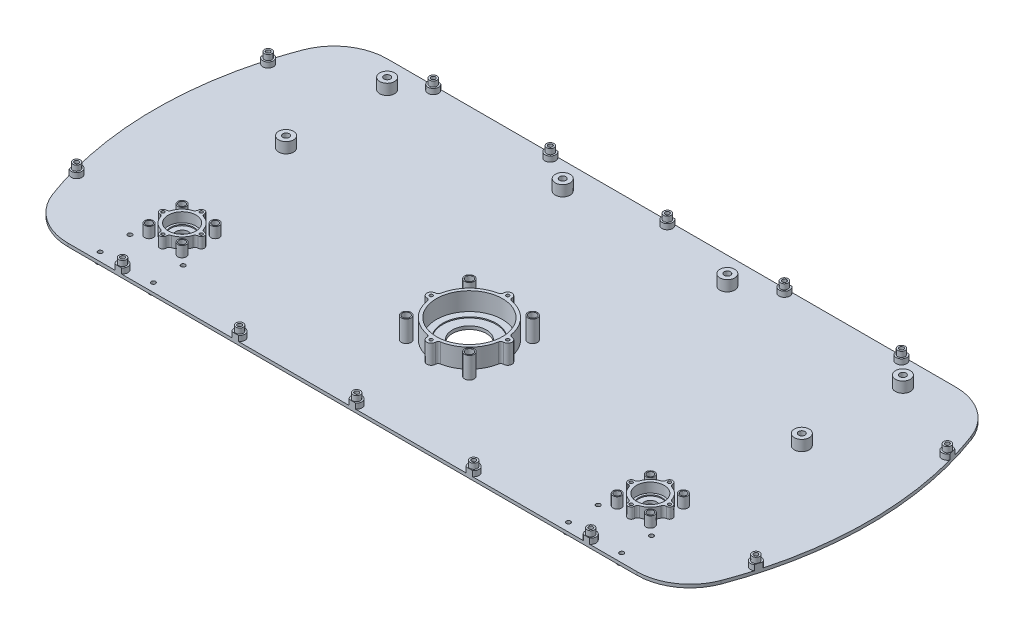
from build123d import *

# Parameters (mm, degrees)
BOSS_EXTRUDE1_DEPTH                          = 3
SKETCH2_R                                    = 6
CUT_EXTRUDE1_DEPTH                           = 10
SKETCH2_3_R                                  = 13
SKETCH2_3_R_2                                = 11
BOSS_EXTRUDE2_DEPTH                          = 1
SKETCH2_4_R                                  = 16
SKETCH2_4_R_2                                = 13
SKETCH2_4_R_3                                = 1.5
BOSS_EXTRUDE3_DEPTH                          = 10
SKETCH3_R                                    = 16
CUT_EXTRUDE8_DEPTH                           = 10
SKETCH3_3_R                                  = 31
SKETCH3_3_R_2                                = 25
BOSS_EXTRUDE4_DEPTH                          = 1
SKETCH3_4_R                                  = 34
SKETCH3_4_R_2                                = 31
SKETCH3_4_R_3                                = 1.5
BOSS_EXTRUDE5_DEPTH                          = 18
SKETCH4_R                                    = 4.5
SKETCH4_R_2                                  = 3.5
SKETCH4_R_3                                  = 2
BOSS_EXTRUDE6_DEPTH                          = 20
CUT_EXTRUDE9_START                           = 20
SKETCH4_3_R                                  = 3.5
SKETCH4_3_R_2                                = 2
CUT_EXTRUDE9_DEPTH                           = 5
SKETCH5_R                                    = 4
SKETCH5_R_2                                  = 3
SKETCH5_R_3                                  = 1.5
BOSS_EXTRUDE7_DEPTH                          = 10
CUT_EXTRUDE10_START                          = 10
SKETCH5_3_R                                  = 3
SKETCH5_3_R_2                                = 1.5
CUT_EXTRUDE10_DEPTH                          = 5
SKETCH8_R                                    = 3.525
SKETCH8_R_2                                  = 2
BOSS_EXTRUDE8_DEPTH                          = 5
SKETCH8_3_R                                  = 2
CUT_EXTRUDE11_DEPTH                          = 10
SKETCH9_R                                    = 2
CUT_EXTRUDE12_DEPTH                          = 10
BOSS_EXTRUDE9_START                          = -3
SKETCH9_3_R                                  = 3.5
SKETCH9_3_R_2                                = 2
BOSS_EXTRUDE9_DEPTH                          = 10
LPATTERN1_COUNT                              = 3
LPATTERN1_PITCH                              = 110
LPATTERN2_COUNT                              = 3
LPATTERN2_PITCH                              = 110
MIRROR4_COPY_1_SKETCH_R                      = 2
MIRROR4_COPY_1_DEPTH                         = 10
MIRROR4_COPY_2_SKETCH_R                      = 2
MIRROR4_COPY_2_DEPTH                         = 10
MIRROR4_START                                = -3
MIRROR4_COPY_3_SKETCH_R                      = 3.5
MIRROR4_COPY_3_SKETCH_R_2                    = 2
MIRROR4_COPY_3_DEPTH                         = 10
MIRROR4_COPY_4_SKETCH_R                      = 3.5
MIRROR4_COPY_4_SKETCH_R_2                    = 2
MIRROR4_COPY_4_DEPTH                         = 10
MIRROR4_COPY_5_SKETCH_R                      = 2
MIRROR4_COPY_5_DEPTH                         = 10
MIRROR4_COPY_6_SKETCH_R                      = 2
MIRROR4_COPY_6_DEPTH                         = 10
MIRROR4_COPY_7_SKETCH_R                      = 2
MIRROR4_COPY_7_DEPTH                         = 10
MIRROR4_COPY_8_SKETCH_R                      = 3.5
MIRROR4_COPY_8_SKETCH_R_2                    = 2
MIRROR4_COPY_8_DEPTH                         = 10
MIRROR4_COPY_9_SKETCH_R                      = 3.5
MIRROR4_COPY_9_SKETCH_R_2                    = 2
MIRROR4_COPY_9_DEPTH                         = 10
MIRROR4_COPY_10_SKETCH_R                     = 2
MIRROR4_COPY_10_DEPTH                        = 10
SKETCH9_5_R                                  = 2
CUT_EXTRUDE13_DEPTH                          = 10
BOSS_EXTRUDE10_START                         = -3
SKETCH9_6_R                                  = 3.5
SKETCH9_6_R_2                                = 2
BOSS_EXTRUDE10_DEPTH                         = 10
MIRROR9_AT_THE_SECOND_PLANE_COPY_1_SKETC_R   = 2
MIRROR9_AT_THE_SECOND_PLANE_COPY_1_DEPTH     = 10
MIRROR9_START                                = -3
MIRROR9_AT_THE_SECOND_PLANE_COPY_2_SKETC_R   = 3.5
MIRROR9_AT_THE_SECOND_PLANE_COPY_2_SKETC_R_2 = 2
MIRROR9_AT_THE_SECOND_PLANE_COPY_2_DEPTH     = 10
BOSS_EXTRUDE11_START                         = -3
SKETCH9_7_R                                  = 3.5
BOSS_EXTRUDE11_DEPTH                         = 5
LPATTERN3_COUNT                              = 3
LPATTERN3_PITCH                              = 110
LPATTERN4_START                              = -3
LPATTERN4_COPY_1_SKETCH_R                    = 3.5
LPATTERN4_COPY_1_DEPTH                       = 5
LPATTERN4_COPY_2_SKETCH_R                    = 3.5
LPATTERN4_COPY_2_DEPTH                       = 5
LPATTERN4_COPY_3_SKETCH_R                    = 3.5
LPATTERN4_COPY_3_DEPTH                       = 5
LPATTERN4_COPY_4_SKETCH_R                    = 3.5
LPATTERN4_COPY_4_DEPTH                       = 5
LPATTERN4_COPY_5_SKETCH_R                    = 3.5
LPATTERN4_COPY_5_DEPTH                       = 5
LPATTERN4_COPY_6_SKETCH_R                    = 3.5
LPATTERN4_COPY_6_DEPTH                       = 5
MIRROR10_START                               = -3
MIRROR10_COPY_1_SKETCH_R                     = 3.5
MIRROR10_COPY_1_DEPTH                        = 5
MIRROR10_COPY_2_SKETCH_R                     = 3.5
MIRROR10_COPY_2_DEPTH                        = 5
MIRROR10_COPY_3_SKETCH_R                     = 3.5
MIRROR10_COPY_3_DEPTH                        = 5
MIRROR10_COPY_4_SKETCH_R                     = 3.5
MIRROR10_COPY_4_DEPTH                        = 5
MIRROR10_COPY_5_SKETCH_R                     = 3.5
MIRROR10_COPY_5_DEPTH                        = 5
MIRROR10_COPY_6_SKETCH_R                     = 3.5
MIRROR10_COPY_6_DEPTH                        = 5
MIRROR10_COPY_7_SKETCH_R                     = 3.5
MIRROR10_COPY_7_DEPTH                        = 5
MIRROR10_COPY_8_SKETCH_R                     = 3.5
MIRROR10_COPY_8_DEPTH                        = 5
BOSS_EXTRUDE12_START                         = -3
SKETCH9_8_R                                  = 3.5
BOSS_EXTRUDE12_DEPTH                         = 5
MIRROR19_START                               = -3
MIRROR19_COPY_1_SKETCH_R                     = 3.5
MIRROR19_COPY_1_DEPTH                        = 5
SKETCH11_R                                   = 3
CUT_EXTRUDE14_DEPTH                          = 10
SKETCH11_3_R                                 = 7
SKETCH11_3_R_2                               = 5
SKETCH11_3_R_3                               = 3
BOSS_EXTRUDE13_DEPTH                         = 10
LPATTERN5_COUNT                              = 2
LPATTERN5_PITCH                              = 165
MIRROR20_COPY_1_SKETCH_R                     = 3
MIRROR20_COPY_1_DEPTH                        = 10
MIRROR20_COPY_2_SKETCH_R                     = 7
MIRROR20_COPY_2_SKETCH_R_2                   = 5
MIRROR20_COPY_2_SKETCH_R_3                   = 3
MIRROR20_COPY_2_DEPTH                        = 10
MIRROR20_COPY_3_SKETCH_R                     = 3
MIRROR20_COPY_3_DEPTH                        = 10
LPATTERN6_COUNT                              = 2
LPATTERN6_PITCH                              = 95
MIRROR21_COPY_1_SKETCH_R                     = 3
MIRROR21_COPY_1_DEPTH                        = 10
MIRROR21_COPY_2_SKETCH_R                     = 7
MIRROR21_COPY_2_SKETCH_R_2                   = 5
MIRROR21_COPY_2_SKETCH_R_3                   = 3
MIRROR21_COPY_2_DEPTH                        = 10
MIRROR21_COPY_3_SKETCH_R                     = 3
MIRROR21_COPY_3_DEPTH                        = 10
MIRROR21_COPY_4_SKETCH_R                     = 7
MIRROR21_COPY_4_SKETCH_R_2                   = 5
MIRROR21_COPY_4_SKETCH_R_3                   = 3
MIRROR21_COPY_4_DEPTH                        = 10


with BuildPart() as part:
    # Sketch1 → Boss-Extrude1 (new body)
    with BuildSketch(Plane(origin=(0, 0, 0), x_dir=(1, 0, 0), z_dir=(0, 1, 0))):
        with BuildLine():
            Line((-267.318125718, 150), (267.318125718, 150))
            ThreePointArc((267.318125718, 150), (295.814333667, 141.084865006), (314.148639988, 117.518645301))
            ThreePointArc((314.148639988, 117.518645301), (335.410196625, 0), (314.148639988, -117.518645301))
            ThreePointArc((314.148639988, -117.518645301), (295.814333667, -141.084865006), (267.318125718, -150))
            Line((267.318125718, -150), (-267.318125718, -150))
            ThreePointArc((-267.318125718, -150), (-295.814333667, -141.084865006), (-314.148639988, -117.518645301))
            ThreePointArc((-314.148639988, -117.518645301), (-335.410196625, 0), (-314.148639988, 117.518645301))
            ThreePointArc((-314.148639988, 117.518645301), (-295.814333667, 141.084865006), (-267.318125718, 150))
        make_face()
    extrude(amount=BOSS_EXTRUDE1_DEPTH)

    # Sketch2 → Cut-Extrude1 (cut)
    with BuildSketch(Plane(origin=(0, 3, 0), x_dir=(1, 0, 0), z_dir=(0, 1, 0))):
        with Locations(Location((-220, -90, 0), (0, 0, 270))):
            Circle(SKETCH2_R)
        with Locations(Location((220, -90, 0), (0, 0, 270))):
            Circle(SKETCH2_R)
    extrude(amount=-CUT_EXTRUDE1_DEPTH, mode=Mode.SUBTRACT)

    # Sketch2_3 → Boss-Extrude2 (add)
    with BuildSketch(Plane(origin=(0, 3, 0), x_dir=(1, 0, 0), z_dir=(0, 1, 0))):
        with Locations(Location((-220, -90, 0), (0, 0, 270))):
            Circle(SKETCH2_3_R)
        with Locations(Location((-220, -90, 0), (0, 0, 270))):
            Circle(SKETCH2_3_R_2, mode=Mode.SUBTRACT)
        with Locations(Location((220, -90, 0), (0, 0, 270))):
            Circle(SKETCH2_3_R)
        with Locations(Location((220, -90, 0), (0, 0, 270))):
            Circle(SKETCH2_3_R_2, mode=Mode.SUBTRACT)
    extrude(amount=BOSS_EXTRUDE2_DEPTH)

    # Sketch2_4 → Boss-Extrude3 (add)
    with BuildSketch(Plane(origin=(0, 3, 0), x_dir=(1, 0, 0), z_dir=(0, 1, 0))):
        with Locations((220, -90)):
            Circle(SKETCH2_4_R)
        with Locations(Location((220, -90, 0), (0, 0, 270))):
            Circle(SKETCH2_4_R_2, mode=Mode.SUBTRACT)
        with BuildLine():
            ThreePointArc((204.138888889, -92.103605077), (204, -90), (204.138888889, -87.896394923))
            ThreePointArc((204.138888889, -87.896394923), (203.159565601, -87.233159272), (202, -87))
            ThreePointArc((202, -87), (199, -90), (202, -93))
            ThreePointArc((202, -93), (203.159565601, -92.766840728), (204.138888889, -92.103605077))
        make_face()
        with Locations(Location((202, -90, 0), (0, 0, 270))):
            Circle(SKETCH2_4_R_3, mode=Mode.SUBTRACT)
        with BuildLine():
            ThreePointArc((217.896394923, -74.138888889), (220, -74), (222.103605077, -74.138888889))
            ThreePointArc((222.103605077, -74.138888889), (222.766840728, -73.159565601), (223, -72))
            ThreePointArc((223, -72), (220, -69), (217, -72))
            ThreePointArc((217, -72), (217.233159272, -73.159565601), (217.896394923, -74.138888889))
        make_face()
        with Locations(Location((220, -72, 0), (0, 0, 270))):
            Circle(SKETCH2_4_R_3, mode=Mode.SUBTRACT)
        with BuildLine():
            ThreePointArc((235.861111111, -87.896394923), (235.96524002, -88.945907447), (236, -90))
            ThreePointArc((236, -90), (235.96524002, -91.054092553), (235.861111111, -92.103605077))
            ThreePointArc((235.861111111, -92.103605077), (236.840434399, -92.766840728), (238, -93))
            ThreePointArc((238, -93), (241, -90), (238, -87))
            ThreePointArc((238, -87), (236.840434399, -87.233159272), (235.861111111, -87.896394923))
        make_face()
        with Locations(Location((238, -90, 0), (0, 0, 270))):
            Circle(SKETCH2_4_R_3, mode=Mode.SUBTRACT)
        with BuildLine():
            ThreePointArc((223, -108), (222.766840728, -106.840434399), (222.103605077, -105.861111111))
            ThreePointArc((222.103605077, -105.861111111), (220, -106), (217.896394923, -105.861111111))
            ThreePointArc((217.896394923, -105.861111111), (217.233159272, -106.840434399), (217, -108))
            ThreePointArc((217, -108), (220, -111), (223, -108))
        make_face()
        with Locations(Location((220, -108, 0), (0, 0, 270))):
            Circle(SKETCH2_4_R_3, mode=Mode.SUBTRACT)
        with BuildLine():
            ThreePointArc((204.138888889, -87.896394923), (204.406304278, -86.417172381), (204.811359026, -84.969574037))
            ThreePointArc((204.811359026, -84.969574037), (203.733952794, -86.439319253), (202, -87))
            ThreePointArc((202, -87), (203.159565601, -87.233159272), (204.138888889, -87.896394923))
        make_face()
        with BuildLine():
            ThreePointArc((202, -93), (203.733952794, -93.560680747), (204.811359026, -95.030425963))
            ThreePointArc((204.811359026, -95.030425963), (204.406304278, -93.582827619), (204.138888889, -92.103605077))
            ThreePointArc((204.138888889, -92.103605077), (203.159565601, -92.766840728), (202, -93))
        make_face()
        with BuildLine():
            ThreePointArc((222.103605077, -74.138888889), (223.582827619, -74.406304278), (225.030425963, -74.811359026))
            ThreePointArc((225.030425963, -74.811359026), (223.560680747, -73.733952794), (223, -72))
            ThreePointArc((223, -72), (222.766840728, -73.159565601), (222.103605077, -74.138888889))
        make_face()
        with BuildLine():
            ThreePointArc((214.969574037, -74.811359026), (216.417172381, -74.406304278), (217.896394923, -74.138888889))
            ThreePointArc((217.896394923, -74.138888889), (217.233159272, -73.159565601), (217, -72))
            ThreePointArc((217, -72), (216.439319253, -73.733952794), (214.969574037, -74.811359026))
        make_face()
        with BuildLine():
            ThreePointArc((235.188640974, -84.969574037), (235.593695722, -86.417172381), (235.861111111, -87.896394923))
            ThreePointArc((235.861111111, -87.896394923), (236.840434399, -87.233159272), (238, -87))
            ThreePointArc((238, -87), (236.266047206, -86.439319253), (235.188640974, -84.969574037))
        make_face()
        with BuildLine():
            ThreePointArc((238, -93), (236.840434399, -92.766840728), (235.861111111, -92.103605077))
            ThreePointArc((235.861111111, -92.103605077), (235.593695722, -93.582827619), (235.188640974, -95.030425963))
            ThreePointArc((235.188640974, -95.030425963), (236.266047206, -93.560680747), (238, -93))
        make_face()
        with BuildLine():
            ThreePointArc((223, -108), (223.560680747, -106.266047206), (225.030425963, -105.188640974))
            ThreePointArc((225.030425963, -105.188640974), (223.582827619, -105.593695722), (222.103605077, -105.861111111))
            ThreePointArc((222.103605077, -105.861111111), (222.766840728, -106.840434399), (223, -108))
        make_face()
        with BuildLine():
            ThreePointArc((217, -108), (217.233159272, -106.840434399), (217.896394923, -105.861111111))
            ThreePointArc((217.896394923, -105.861111111), (216.417172381, -105.593695722), (214.969574037, -105.188640974))
            ThreePointArc((214.969574037, -105.188640974), (216.439319253, -106.266047206), (217, -108))
        make_face()
    boss_extrude3 = extrude(amount=BOSS_EXTRUDE3_DEPTH)

    # Sketch3 → Cut-Extrude8 (cut)
    with BuildSketch(Plane(origin=(0, 3, 0), x_dir=(1, 0, 0), z_dir=(0, 1, 0))):
        with Locations(Location((0, -40, 0), (0, 0, 270))):
            Circle(SKETCH3_R)
    extrude(amount=-CUT_EXTRUDE8_DEPTH, mode=Mode.SUBTRACT)

    # Sketch3_3 → Boss-Extrude4 (add)
    with BuildSketch(Plane(origin=(0, 3, 0), x_dir=(1, 0, 0), z_dir=(0, 1, 0))):
        with Locations(Location((0, -40, 0), (0, 0, 270))):
            Circle(SKETCH3_3_R)
        with Locations(Location((0, -40, 0), (0, 0, 270))):
            Circle(SKETCH3_3_R_2, mode=Mode.SUBTRACT)
    extrude(amount=BOSS_EXTRUDE4_DEPTH)

    # Sketch3_4 → Boss-Extrude5 (add)
    with BuildSketch(Plane(origin=(0, 3, 0), x_dir=(1, 0, 0), z_dir=(0, 1, 0))):
        with Locations((0, -40)):
            Circle(SKETCH3_4_R)
        with Locations(Location((0, -40, 0), (0, 0, 270))):
            Circle(SKETCH3_4_R_2, mode=Mode.SUBTRACT)
        with BuildLine():
            ThreePointArc((33.833333333, -36.6376265), (33.958307771, -38.316749177), (34, -40))
            ThreePointArc((34, -40), (33.958307771, -41.683250823), (33.833333333, -43.3623735))
            ThreePointArc((33.833333333, -43.3623735), (34.870728996, -43.837283805), (36, -44))
            ThreePointArc((36, -44), (40, -40), (36, -36))
            ThreePointArc((36, -36), (34.870728996, -36.162716195), (33.833333333, -36.6376265))
        make_face()
        with Locations(Location((36, -40, 0), (0, 0, 270))):
            Circle(SKETCH3_4_R_3, mode=Mode.SUBTRACT)
        with BuildLine():
            ThreePointArc((4, -76), (3.837283805, -74.870728996), (3.3623735, -73.833333333))
            ThreePointArc((3.3623735, -73.833333333), (0, -74), (-3.3623735, -73.833333333))
            ThreePointArc((-3.3623735, -73.833333333), (-3.837283805, -74.870728996), (-4, -76))
            ThreePointArc((-4, -76), (0, -80), (4, -76))
        make_face()
        with Locations(Location((0, -76, 0), (0, 0, 270))):
            Circle(SKETCH3_4_R_3, mode=Mode.SUBTRACT)
        with BuildLine():
            ThreePointArc((-33.833333333, -43.3623735), (-34, -40), (-33.833333333, -36.6376265))
            ThreePointArc((-33.833333333, -36.6376265), (-34.870728996, -36.162716195), (-36, -36))
            ThreePointArc((-36, -36), (-40, -40), (-36, -44))
            ThreePointArc((-36, -44), (-34.870728996, -43.837283805), (-33.833333333, -43.3623735))
        make_face()
        with Locations(Location((-36, -40, 0), (0, 0, 270))):
            Circle(SKETCH3_4_R_3, mode=Mode.SUBTRACT)
        with BuildLine():
            ThreePointArc((-3.3623735, -6.166666667), (0, -6), (3.3623735, -6.166666667))
            ThreePointArc((3.3623735, -6.166666667), (3.837283805, -5.129271004), (4, -4))
            ThreePointArc((4, -4), (0, 0), (-4, -4))
            ThreePointArc((-4, -4), (-3.837283805, -5.129271004), (-3.3623735, -6.166666667))
        make_face()
        with Locations(Location((0, -4, 0), (0, 0, 270))):
            Circle(SKETCH3_4_R_3, mode=Mode.SUBTRACT)
        with BuildLine():
            ThreePointArc((-33.833333333, -36.6376265), (-33.666453643, -35.249221212), (-33.442622951, -33.868852459))
            ThreePointArc((-33.442622951, -33.868852459), (-34.335520561, -35.397375327), (-36, -36))
            ThreePointArc((-36, -36), (-34.870728996, -36.162716195), (-33.833333333, -36.6376265))
        make_face()
        with BuildLine():
            ThreePointArc((-36, -44), (-34.335520561, -44.602624673), (-33.442622951, -46.131147541))
            ThreePointArc((-33.442622951, -46.131147541), (-33.666453643, -44.750778788), (-33.833333333, -43.3623735))
            ThreePointArc((-33.833333333, -43.3623735), (-34.870728996, -43.837283805), (-36, -44))
        make_face()
        with BuildLine():
            ThreePointArc((-6.131147541, -6.557377049), (-4.750778788, -6.333546357), (-3.3623735, -6.166666667))
            ThreePointArc((-3.3623735, -6.166666667), (-3.837283805, -5.129271004), (-4, -4))
            ThreePointArc((-4, -4), (-4.602624673, -5.664479439), (-6.131147541, -6.557377049))
        make_face()
        with BuildLine():
            ThreePointArc((3.3623735, -6.166666667), (4.750778788, -6.333546357), (6.131147541, -6.557377049))
            ThreePointArc((6.131147541, -6.557377049), (4.602624673, -5.664479439), (4, -4))
            ThreePointArc((4, -4), (3.837283805, -5.129271004), (3.3623735, -6.166666667))
        make_face()
        with BuildLine():
            ThreePointArc((36, -44), (34.870728996, -43.837283805), (33.833333333, -43.3623735))
            ThreePointArc((33.833333333, -43.3623735), (33.666453643, -44.750778788), (33.442622951, -46.131147541))
            ThreePointArc((33.442622951, -46.131147541), (34.335520561, -44.602624673), (36, -44))
        make_face()
        with BuildLine():
            ThreePointArc((33.442622951, -33.868852459), (33.666453643, -35.249221212), (33.833333333, -36.6376265))
            ThreePointArc((33.833333333, -36.6376265), (34.870728996, -36.162716195), (36, -36))
            ThreePointArc((36, -36), (34.335520561, -35.397375327), (33.442622951, -33.868852459))
        make_face()
        with BuildLine():
            ThreePointArc((4, -76), (4.602624673, -74.335520561), (6.131147541, -73.442622951))
            ThreePointArc((6.131147541, -73.442622951), (4.750778788, -73.666453643), (3.3623735, -73.833333333))
            ThreePointArc((3.3623735, -73.833333333), (3.837283805, -74.870728996), (4, -76))
        make_face()
        with BuildLine():
            ThreePointArc((-4, -76), (-3.837283805, -74.870728996), (-3.3623735, -73.833333333))
            ThreePointArc((-3.3623735, -73.833333333), (-4.750778788, -73.666453643), (-6.131147541, -73.442622951))
            ThreePointArc((-6.131147541, -73.442622951), (-4.602624673, -74.335520561), (-4, -76))
        make_face()
    extrude(amount=BOSS_EXTRUDE5_DEPTH)

    # Mirror1: Boss-Extrude3 across plane
    add(boss_extrude3.mirror(Plane(origin=(0, 0, 0), x_dir=(0, 0, 1), z_dir=(1, 0, 0))))

    # Sketch4 → Boss-Extrude6 (add)
    with BuildSketch(Plane(origin=(0, 3, 0), x_dir=(1, 0, 0), z_dir=(0, 1, 0))):
        with Locations(Location((29.69848481, -10.30151519, 0), (0, 0, 270))):
            Circle(SKETCH4_R)
        with Locations((29.69848481, -10.30151519)):
            Circle(SKETCH4_R_2, mode=Mode.SUBTRACT)
        with Locations((29.69848481, -10.30151519)):
            Circle(SKETCH4_R_2)
        with Locations(Location((29.69848481, -10.30151519, 0), (0, 0, 270))):
            Circle(SKETCH4_R_3, mode=Mode.SUBTRACT)
        with Locations(Location((-29.69848481, -10.30151519, 0), (0, 0, 270))):
            Circle(SKETCH4_R)
        with Locations((-29.69848481, -10.30151519)):
            Circle(SKETCH4_R_2, mode=Mode.SUBTRACT)
        with Locations((-29.69848481, -10.30151519)):
            Circle(SKETCH4_R_2)
        with Locations(Location((-29.69848481, -10.30151519, 0), (0, 0, 270))):
            Circle(SKETCH4_R_3, mode=Mode.SUBTRACT)
        with Locations(Location((29.69848481, -69.69848481, 0), (0, 0, 270))):
            Circle(SKETCH4_R)
        with Locations((29.69848481, -69.69848481)):
            Circle(SKETCH4_R_2, mode=Mode.SUBTRACT)
        with Locations((29.69848481, -69.69848481)):
            Circle(SKETCH4_R_2)
        with Locations(Location((29.69848481, -69.69848481, 0), (0, 0, 270))):
            Circle(SKETCH4_R_3, mode=Mode.SUBTRACT)
        with Locations(Location((-29.69848481, -69.69848481, 0), (0, 0, 270))):
            Circle(SKETCH4_R)
        with Locations((-29.69848481, -69.69848481)):
            Circle(SKETCH4_R_2, mode=Mode.SUBTRACT)
        with Locations((-29.69848481, -69.69848481)):
            Circle(SKETCH4_R_2)
        with Locations(Location((-29.69848481, -69.69848481, 0), (0, 0, 270))):
            Circle(SKETCH4_R_3, mode=Mode.SUBTRACT)
    extrude(amount=BOSS_EXTRUDE6_DEPTH)

    # Sketch4_3 → Cut-Extrude9 (cut)
    with BuildSketch(Plane(origin=(0, 3, 0), x_dir=(1, 0, 0), z_dir=(0, 1, 0)).offset(CUT_EXTRUDE9_START)):
        with Locations(Location((-29.69848481, -10.30151519, 0), (0, 0, 270))):
            Circle(SKETCH4_3_R)
        with Locations(Location((-29.69848481, -10.30151519, 0), (0, 0, 270))):
            Circle(SKETCH4_3_R_2, mode=Mode.SUBTRACT)
        with Locations(Location((29.69848481, -10.30151519, 0), (0, 0, 270))):
            Circle(SKETCH4_3_R)
        with Locations(Location((29.69848481, -10.30151519, 0), (0, 0, 270))):
            Circle(SKETCH4_3_R_2, mode=Mode.SUBTRACT)
        with Locations(Location((29.69848481, -69.69848481, 0), (0, 0, 270))):
            Circle(SKETCH4_3_R)
        with Locations(Location((29.69848481, -69.69848481, 0), (0, 0, 270))):
            Circle(SKETCH4_3_R_2, mode=Mode.SUBTRACT)
        with Locations(Location((-29.69848481, -69.69848481, 0), (0, 0, 270))):
            Circle(SKETCH4_3_R)
        with Locations(Location((-29.69848481, -69.69848481, 0), (0, 0, 270))):
            Circle(SKETCH4_3_R_2, mode=Mode.SUBTRACT)
    extrude(amount=-CUT_EXTRUDE9_DEPTH, mode=Mode.SUBTRACT)

    # Sketch5 → Boss-Extrude7 (add)
    with BuildSketch(Plane(origin=(0, 3, 0), x_dir=(1, 0, 0), z_dir=(0, 1, 0))):
        with Locations(Location((235.556349186, -74.443650814, 0), (0, 0, 270))):
            Circle(SKETCH5_R)
        with Locations((235.556349186, -74.443650814)):
            Circle(SKETCH5_R_2, mode=Mode.SUBTRACT)
        with Locations((235.556349186, -74.443650814)):
            Circle(SKETCH5_R_2)
        with Locations(Location((235.556349186, -74.443650814, 0), (0, 0, 270))):
            Circle(SKETCH5_R_3, mode=Mode.SUBTRACT)
        with Locations(Location((204.443650814, -74.443650814, 0), (0, 0, 270))):
            Circle(SKETCH5_R)
        with Locations((204.443650814, -74.443650814)):
            Circle(SKETCH5_R_2, mode=Mode.SUBTRACT)
        with Locations((204.443650814, -74.443650814)):
            Circle(SKETCH5_R_2)
        with Locations(Location((204.443650814, -74.443650814, 0), (0, 0, 270))):
            Circle(SKETCH5_R_3, mode=Mode.SUBTRACT)
        with Locations(Location((235.556349186, -105.556349186, 0), (0, 0, 270))):
            Circle(SKETCH5_R)
        with Locations((235.556349186, -105.556349186)):
            Circle(SKETCH5_R_2, mode=Mode.SUBTRACT)
        with Locations((235.556349186, -105.556349186)):
            Circle(SKETCH5_R_2)
        with Locations(Location((235.556349186, -105.556349186, 0), (0, 0, 270))):
            Circle(SKETCH5_R_3, mode=Mode.SUBTRACT)
        with Locations(Location((204.443650814, -105.556349186, 0), (0, 0, 270))):
            Circle(SKETCH5_R)
        with Locations((204.443650814, -105.556349186)):
            Circle(SKETCH5_R_2, mode=Mode.SUBTRACT)
        with Locations((204.443650814, -105.556349186)):
            Circle(SKETCH5_R_2)
        with Locations(Location((204.443650814, -105.556349186, 0), (0, 0, 270))):
            Circle(SKETCH5_R_3, mode=Mode.SUBTRACT)
    boss_extrude7 = extrude(amount=BOSS_EXTRUDE7_DEPTH)

    # Sketch5_3 → Cut-Extrude10 (cut)
    with BuildSketch(Plane(origin=(0, 3, 0), x_dir=(1, 0, 0), z_dir=(0, 1, 0)).offset(CUT_EXTRUDE10_START)):
        with Locations(Location((204.443650814, -105.556349186, 0), (0, 0, 270))):
            Circle(SKETCH5_3_R)
        with Locations(Location((204.443650814, -105.556349186, 0), (0, 0, 270))):
            Circle(SKETCH5_3_R_2, mode=Mode.SUBTRACT)
        with Locations(Location((204.443650814, -74.443650814, 0), (0, 0, 270))):
            Circle(SKETCH5_3_R)
        with Locations(Location((204.443650814, -74.443650814, 0), (0, 0, 270))):
            Circle(SKETCH5_3_R_2, mode=Mode.SUBTRACT)
        with Locations(Location((235.556349186, -74.443650814, 0), (0, 0, 270))):
            Circle(SKETCH5_3_R)
        with Locations(Location((235.556349186, -74.443650814, 0), (0, 0, 270))):
            Circle(SKETCH5_3_R_2, mode=Mode.SUBTRACT)
        with Locations(Location((235.556349186, -105.556349186, 0), (0, 0, 270))):
            Circle(SKETCH5_3_R)
        with Locations(Location((235.556349186, -105.556349186, 0), (0, 0, 270))):
            Circle(SKETCH5_3_R_2, mode=Mode.SUBTRACT)
    cut_extrude10 = extrude(amount=-CUT_EXTRUDE10_DEPTH, mode=Mode.SUBTRACT)

    # Mirror2: Boss-Extrude7, Cut-Extrude10 across plane
    add(boss_extrude7.mirror(Plane(origin=(0, 0, 0), x_dir=(0, 0, 1), z_dir=(1, 0, 0))))
    add(cut_extrude10.mirror(Plane(origin=(0, 0, 0), x_dir=(0, 0, 1), z_dir=(1, 0, 0))), mode=Mode.SUBTRACT)

    # Sketch8 → Boss-Extrude8 (add)
    with BuildSketch(Plane.XZ):
        with Locations(Location((-245, 142, 0), (0, 0, 90))):
            Circle(SKETCH8_R)
        with Locations(Location((-245, 142, 0), (0, 0, 270))):
            Circle(SKETCH8_R_2, mode=Mode.SUBTRACT)
        with Locations(Location((-195, 142, 0), (0, 0, 90))):
            Circle(SKETCH8_R)
        with Locations(Location((-195, 142, 0), (0, 0, 270))):
            Circle(SKETCH8_R_2, mode=Mode.SUBTRACT)
        with Locations(Location((-195, 114, 0), (0, 0, 90))):
            Circle(SKETCH8_R)
        with Locations(Location((-195, 114, 0), (0, 0, 270))):
            Circle(SKETCH8_R_2, mode=Mode.SUBTRACT)
        with Locations(Location((-245, 114, 0), (0, 0, 90))):
            Circle(SKETCH8_R)
        with Locations(Location((-245, 114, 0), (0, 0, 270))):
            Circle(SKETCH8_R_2, mode=Mode.SUBTRACT)
    boss_extrude8 = extrude(amount=BOSS_EXTRUDE8_DEPTH)

    # Sketch8_3 → Cut-Extrude11 (cut)
    with BuildSketch(Plane.XZ):
        with Locations(Location((-195, 142, 0), (0, 0, 90))):
            Circle(SKETCH8_3_R)
        with Locations(Location((-195, 114, 0), (0, 0, 90))):
            Circle(SKETCH8_3_R)
        with Locations(Location((-245, 114, 0), (0, 0, 90))):
            Circle(SKETCH8_3_R)
        with Locations(Location((-245, 142, 0), (0, 0, 90))):
            Circle(SKETCH8_3_R)
    cut_extrude11 = extrude(amount=-CUT_EXTRUDE11_DEPTH, mode=Mode.SUBTRACT)

    # Mirror3: Boss-Extrude8, Cut-Extrude11 across plane
    add(boss_extrude8.mirror(Plane(origin=(0, 0, 0), x_dir=(0, 0, 1), z_dir=(1, 0, 0))))
    add(cut_extrude11.mirror(Plane(origin=(0, 0, 0), x_dir=(0, 0, 1), z_dir=(1, 0, 0))), mode=Mode.SUBTRACT)

    # Sketch9 → Cut-Extrude12 (cut)
    with BuildSketch(Plane.XZ):
        with Locations(Location((0, -146, 0), (0, 0, 270))):
            Circle(SKETCH9_R)
    cut_extrude12 = extrude(amount=-CUT_EXTRUDE12_DEPTH, mode=Mode.SUBTRACT)

    # Sketch9_3 → Boss-Extrude9 (add)
    with BuildSketch(Plane.XZ.offset(BOSS_EXTRUDE9_START)):
        with Locations(Location((0, -146, 0), (0, 0, 90))):
            Circle(SKETCH9_3_R)
        with Locations(Location((0, -146, 0), (0, 0, 270))):
            Circle(SKETCH9_3_R_2, mode=Mode.SUBTRACT)
    boss_extrude9 = extrude(amount=-BOSS_EXTRUDE9_DEPTH)

    # LPattern1: Cut-Extrude12, Boss-Extrude9 ×3
    with Locations(*[(i * LPATTERN1_PITCH, 0, 0) for i in range(1, LPATTERN1_COUNT)]):
        add(cut_extrude12, mode=Mode.SUBTRACT)
        add(boss_extrude9)

    # LPattern2: Cut-Extrude12, Boss-Extrude9 ×3
    with Locations(*[(-i * LPATTERN2_PITCH, 0, 0) for i in range(1, LPATTERN2_COUNT)]):
        add(cut_extrude12, mode=Mode.SUBTRACT)
        add(boss_extrude9)

    # Mirror4: Boss-Extrude9 across plane
    add(boss_extrude9.mirror(Plane.XY))

    # Mirror4 copy 1 sketch → Mirror4 copy 1 (cut)
    with BuildSketch(Plane(origin=(110, 0, 0), x_dir=(1, 0, 0), z_dir=(0, -1, 0))):
        with Locations((0, 146)):
            Circle(MIRROR4_COPY_1_SKETCH_R)
    extrude(amount=-MIRROR4_COPY_1_DEPTH, mode=Mode.SUBTRACT)

    # Mirror4 copy 2 sketch → Mirror4 copy 2 (cut)
    with BuildSketch(Plane(origin=(220, 0, 0), x_dir=(1, 0, 0), z_dir=(0, -1, 0))):
        with Locations((0, 146)):
            Circle(MIRROR4_COPY_2_SKETCH_R)
    extrude(amount=-MIRROR4_COPY_2_DEPTH, mode=Mode.SUBTRACT)

    # Mirror4 copy 3 sketch → Mirror4 copy 3 (add)
    with BuildSketch(Plane(origin=(110, 0, 0), x_dir=(1, 0, 0), z_dir=(0, -1, 0)).offset(MIRROR4_START)):
        with Locations((0, 146)):
            Circle(MIRROR4_COPY_3_SKETCH_R)
        with Locations((0, 146)):
            Circle(MIRROR4_COPY_3_SKETCH_R_2, mode=Mode.SUBTRACT)
    extrude(amount=-MIRROR4_COPY_3_DEPTH)

    # Mirror4 copy 4 sketch → Mirror4 copy 4 (add)
    with BuildSketch(Plane(origin=(220, 0, 0), x_dir=(1, 0, 0), z_dir=(0, -1, 0)).offset(MIRROR4_START)):
        with Locations((0, 146)):
            Circle(MIRROR4_COPY_4_SKETCH_R)
        with Locations((0, 146)):
            Circle(MIRROR4_COPY_4_SKETCH_R_2, mode=Mode.SUBTRACT)
    extrude(amount=-MIRROR4_COPY_4_DEPTH)

    # Mirror4 copy 5 sketch → Mirror4 copy 5 (cut)
    with BuildSketch(Plane.XZ):
        with Locations((0, 146)):
            Circle(MIRROR4_COPY_5_SKETCH_R)
    extrude(amount=-MIRROR4_COPY_5_DEPTH, mode=Mode.SUBTRACT)

    # Mirror4 copy 6 sketch → Mirror4 copy 6 (cut)
    with BuildSketch(Plane(origin=(-110, 0, 0), x_dir=(1, 0, 0), z_dir=(0, -1, 0))):
        with Locations((0, 146)):
            Circle(MIRROR4_COPY_6_SKETCH_R)
    extrude(amount=-MIRROR4_COPY_6_DEPTH, mode=Mode.SUBTRACT)

    # Mirror4 copy 7 sketch → Mirror4 copy 7 (cut)
    with BuildSketch(Plane(origin=(-220, 0, 0), x_dir=(1, 0, 0), z_dir=(0, -1, 0))):
        with Locations((0, 146)):
            Circle(MIRROR4_COPY_7_SKETCH_R)
    extrude(amount=-MIRROR4_COPY_7_DEPTH, mode=Mode.SUBTRACT)

    # Mirror4 copy 8 sketch → Mirror4 copy 8 (add)
    with BuildSketch(Plane(origin=(-110, 0, 0), x_dir=(1, 0, 0), z_dir=(0, -1, 0)).offset(MIRROR4_START)):
        with Locations((0, 146)):
            Circle(MIRROR4_COPY_8_SKETCH_R)
        with Locations((0, 146)):
            Circle(MIRROR4_COPY_8_SKETCH_R_2, mode=Mode.SUBTRACT)
    extrude(amount=-MIRROR4_COPY_8_DEPTH)

    # Mirror4 copy 9 sketch → Mirror4 copy 9 (add)
    with BuildSketch(Plane(origin=(-220, 0, 0), x_dir=(1, 0, 0), z_dir=(0, -1, 0)).offset(MIRROR4_START)):
        with Locations((0, 146)):
            Circle(MIRROR4_COPY_9_SKETCH_R)
        with Locations((0, 146)):
            Circle(MIRROR4_COPY_9_SKETCH_R_2, mode=Mode.SUBTRACT)
    extrude(amount=-MIRROR4_COPY_9_DEPTH)

    # Mirror4 copy 10 sketch → Mirror4 copy 10 (cut)
    with BuildSketch(Plane.XZ):
        with Locations((0, 146)):
            Circle(MIRROR4_COPY_10_SKETCH_R)
    extrude(amount=-MIRROR4_COPY_10_DEPTH, mode=Mode.SUBTRACT)

    # Sketch9_5 → Cut-Extrude13 (cut)
    with BuildSketch(Plane.XZ):
        with Locations(Location((319.148639988, -90, 0), (0, 0, 270))):
            Circle(SKETCH9_5_R)
    cut_extrude13 = extrude(amount=-CUT_EXTRUDE13_DEPTH, mode=Mode.SUBTRACT)

    # Sketch9_6 → Boss-Extrude10 (add)
    with BuildSketch(Plane.XZ.offset(BOSS_EXTRUDE10_START)):
        with Locations(Location((319.148639988, -90, 0), (0, 0, 90))):
            Circle(SKETCH9_6_R)
        with Locations(Location((319.148639988, -90, 0), (0, 0, 270))):
            Circle(SKETCH9_6_R_2, mode=Mode.SUBTRACT)
    boss_extrude10 = extrude(amount=-BOSS_EXTRUDE10_DEPTH)

    # Mirror9: Cut-Extrude13, Boss-Extrude10 across plane
    add(cut_extrude13.mirror(Plane.XY), mode=Mode.SUBTRACT)
    add(boss_extrude10.mirror(Plane.XY))

    # Mirror9 at the second plane: Cut-Extrude13, Boss-Extrude10 across plane
    add(cut_extrude13.mirror(Plane(origin=(0, 0, 0), x_dir=(0, 0, 1), z_dir=(1, 0, 0))), mode=Mode.SUBTRACT)
    add(boss_extrude10.mirror(Plane(origin=(0, 0, 0), x_dir=(0, 0, 1), z_dir=(1, 0, 0))))

    # Mirror9 at the second plane copy 1 sketc → Mirror9 at the second plane copy 1 (cut)
    with BuildSketch(Plane(origin=(0, 0, 0), x_dir=(-1, 0, 0), z_dir=(0, -1, 0))):
        with Locations(Location((319.148639988, -90, 0), (0, 0, 270))):
            Circle(MIRROR9_AT_THE_SECOND_PLANE_COPY_1_SKETC_R)
    extrude(amount=-MIRROR9_AT_THE_SECOND_PLANE_COPY_1_DEPTH, mode=Mode.SUBTRACT)

    # Mirror9 at the second plane copy 2 sketc → Mirror9 at the second plane copy 2 (add)
    with BuildSketch(Plane(origin=(0, 0, 0), x_dir=(-1, 0, 0), z_dir=(0, -1, 0)).offset(MIRROR9_START)):
        with Locations(Location((319.148639988, -90, 0), (0, 0, 90))):
            Circle(MIRROR9_AT_THE_SECOND_PLANE_COPY_2_SKETC_R)
        with Locations(Location((319.148639988, -90, 0), (0, 0, 270))):
            Circle(MIRROR9_AT_THE_SECOND_PLANE_COPY_2_SKETC_R_2, mode=Mode.SUBTRACT)
    extrude(amount=-MIRROR9_AT_THE_SECOND_PLANE_COPY_2_DEPTH)

    # Sketch9_7 → Boss-Extrude11 (add)
    with BuildSketch(Plane.XZ.offset(BOSS_EXTRUDE11_START)):
        with BuildLine():
            ThreePointArc((5, -146), (-2.236067977, -141.527864045), (-3, -150))
            Line((-3, -150), (3, -150))
            ThreePointArc((3, -150), (4.472135955, -148.236067977), (5, -146))
        make_face()
        with Locations(Location((0, -146, 0), (0, 0, 90))):
            Circle(SKETCH9_7_R, mode=Mode.SUBTRACT)
    boss_extrude11 = extrude(amount=-BOSS_EXTRUDE11_DEPTH)

    # LPattern3: Boss-Extrude11 ×3
    with Locations(*[(i * LPATTERN3_PITCH, 0, 0) for i in range(1, LPATTERN3_COUNT)]):
        add(boss_extrude11)

    # LPattern4 copy 1 sketch → LPattern4 copy 1 (add)
    with BuildSketch(Plane.XZ.offset(LPATTERN4_START)):
        with BuildLine():
            ThreePointArc((5, -146), (-2.236067977, -141.527864045), (-3, -150))
            Line((-3, -150), (3, -150))
            ThreePointArc((3, -150), (4.472135955, -148.236067977), (5, -146))
        make_face()
        with Locations(Location((0, -146, 0), (0, 0, 90))):
            Circle(LPATTERN4_COPY_1_SKETCH_R, mode=Mode.SUBTRACT)
    extrude(amount=-LPATTERN4_COPY_1_DEPTH)

    # LPattern4 copy 2 sketch → LPattern4 copy 2 (add)
    with BuildSketch(Plane(origin=(-110, 0, 0), x_dir=(1, 0, 0), z_dir=(0, -1, 0)).offset(LPATTERN4_START)):
        with BuildLine():
            ThreePointArc((5, -146), (-2.236067977, -141.527864045), (-3, -150))
            Line((-3, -150), (3, -150))
            ThreePointArc((3, -150), (4.472135955, -148.236067977), (5, -146))
        make_face()
        with Locations(Location((0, -146, 0), (0, 0, 90))):
            Circle(LPATTERN4_COPY_2_SKETCH_R, mode=Mode.SUBTRACT)
    extrude(amount=-LPATTERN4_COPY_2_DEPTH)

    # LPattern4 copy 3 sketch → LPattern4 copy 3 (add)
    with BuildSketch(Plane(origin=(110, 0, 0), x_dir=(1, 0, 0), z_dir=(0, -1, 0)).offset(LPATTERN4_START)):
        with BuildLine():
            ThreePointArc((5, -146), (-2.236067977, -141.527864045), (-3, -150))
            Line((-3, -150), (3, -150))
            ThreePointArc((3, -150), (4.472135955, -148.236067977), (5, -146))
        make_face()
        with Locations(Location((0, -146, 0), (0, 0, 90))):
            Circle(LPATTERN4_COPY_3_SKETCH_R, mode=Mode.SUBTRACT)
    extrude(amount=-LPATTERN4_COPY_3_DEPTH)

    # LPattern4 copy 4 sketch → LPattern4 copy 4 (add)
    with BuildSketch(Plane.XZ.offset(LPATTERN4_START)):
        with BuildLine():
            ThreePointArc((5, -146), (-2.236067977, -141.527864045), (-3, -150))
            Line((-3, -150), (3, -150))
            ThreePointArc((3, -150), (4.472135955, -148.236067977), (5, -146))
        make_face()
        with Locations(Location((0, -146, 0), (0, 0, 90))):
            Circle(LPATTERN4_COPY_4_SKETCH_R, mode=Mode.SUBTRACT)
    extrude(amount=-LPATTERN4_COPY_4_DEPTH)

    # LPattern4 copy 5 sketch → LPattern4 copy 5 (add)
    with BuildSketch(Plane(origin=(-110, 0, 0), x_dir=(1, 0, 0), z_dir=(0, -1, 0)).offset(LPATTERN4_START)):
        with BuildLine():
            ThreePointArc((5, -146), (-2.236067977, -141.527864045), (-3, -150))
            Line((-3, -150), (3, -150))
            ThreePointArc((3, -150), (4.472135955, -148.236067977), (5, -146))
        make_face()
        with Locations(Location((0, -146, 0), (0, 0, 90))):
            Circle(LPATTERN4_COPY_5_SKETCH_R, mode=Mode.SUBTRACT)
    extrude(amount=-LPATTERN4_COPY_5_DEPTH)

    # LPattern4 copy 6 sketch → LPattern4 copy 6 (add)
    with BuildSketch(Plane(origin=(-220, 0, 0), x_dir=(1, 0, 0), z_dir=(0, -1, 0)).offset(LPATTERN4_START)):
        with BuildLine():
            ThreePointArc((5, -146), (-2.236067977, -141.527864045), (-3, -150))
            Line((-3, -150), (3, -150))
            ThreePointArc((3, -150), (4.472135955, -148.236067977), (5, -146))
        make_face()
        with Locations(Location((0, -146, 0), (0, 0, 90))):
            Circle(LPATTERN4_COPY_6_SKETCH_R, mode=Mode.SUBTRACT)
    extrude(amount=-LPATTERN4_COPY_6_DEPTH)

    # Mirror10: Boss-Extrude11 across plane
    add(boss_extrude11.mirror(Plane.XY))

    # Mirror10 copy 1 sketch → Mirror10 copy 1 (add)
    with BuildSketch(Plane(origin=(110, 0, 0), x_dir=(1, 0, 0), z_dir=(0, -1, 0)).offset(MIRROR10_START)):
        with BuildLine():
            ThreePointArc((5, 146), (-2.236067977, 141.527864045), (-3, 150))
            Line((-3, 150), (3, 150))
            ThreePointArc((3, 150), (4.472135955, 148.236067977), (5, 146))
        make_face()
        with Locations((0, 146)):
            Circle(MIRROR10_COPY_1_SKETCH_R, mode=Mode.SUBTRACT)
    extrude(amount=-MIRROR10_COPY_1_DEPTH)

    # Mirror10 copy 2 sketch → Mirror10 copy 2 (add)
    with BuildSketch(Plane(origin=(220, 0, 0), x_dir=(1, 0, 0), z_dir=(0, -1, 0)).offset(MIRROR10_START)):
        with BuildLine():
            ThreePointArc((5, 146), (-2.236067977, 141.527864045), (-3, 150))
            Line((-3, 150), (3, 150))
            ThreePointArc((3, 150), (4.472135955, 148.236067977), (5, 146))
        make_face()
        with Locations((0, 146)):
            Circle(MIRROR10_COPY_2_SKETCH_R, mode=Mode.SUBTRACT)
    extrude(amount=-MIRROR10_COPY_2_DEPTH)

    # Mirror10 copy 3 sketch → Mirror10 copy 3 (add)
    with BuildSketch(Plane.XZ.offset(MIRROR10_START)):
        with BuildLine():
            ThreePointArc((5, 146), (-2.236067977, 141.527864045), (-3, 150))
            Line((-3, 150), (3, 150))
            ThreePointArc((3, 150), (4.472135955, 148.236067977), (5, 146))
        make_face()
        with Locations((0, 146)):
            Circle(MIRROR10_COPY_3_SKETCH_R, mode=Mode.SUBTRACT)
    extrude(amount=-MIRROR10_COPY_3_DEPTH)

    # Mirror10 copy 4 sketch → Mirror10 copy 4 (add)
    with BuildSketch(Plane(origin=(-110, 0, 0), x_dir=(1, 0, 0), z_dir=(0, -1, 0)).offset(MIRROR10_START)):
        with BuildLine():
            ThreePointArc((5, 146), (-2.236067977, 141.527864045), (-3, 150))
            Line((-3, 150), (3, 150))
            ThreePointArc((3, 150), (4.472135955, 148.236067977), (5, 146))
        make_face()
        with Locations((0, 146)):
            Circle(MIRROR10_COPY_4_SKETCH_R, mode=Mode.SUBTRACT)
    extrude(amount=-MIRROR10_COPY_4_DEPTH)

    # Mirror10 copy 5 sketch → Mirror10 copy 5 (add)
    with BuildSketch(Plane(origin=(110, 0, 0), x_dir=(1, 0, 0), z_dir=(0, -1, 0)).offset(MIRROR10_START)):
        with BuildLine():
            ThreePointArc((5, 146), (-2.236067977, 141.527864045), (-3, 150))
            Line((-3, 150), (3, 150))
            ThreePointArc((3, 150), (4.472135955, 148.236067977), (5, 146))
        make_face()
        with Locations((0, 146)):
            Circle(MIRROR10_COPY_5_SKETCH_R, mode=Mode.SUBTRACT)
    extrude(amount=-MIRROR10_COPY_5_DEPTH)

    # Mirror10 copy 6 sketch → Mirror10 copy 6 (add)
    with BuildSketch(Plane.XZ.offset(MIRROR10_START)):
        with BuildLine():
            ThreePointArc((5, 146), (-2.236067977, 141.527864045), (-3, 150))
            Line((-3, 150), (3, 150))
            ThreePointArc((3, 150), (4.472135955, 148.236067977), (5, 146))
        make_face()
        with Locations((0, 146)):
            Circle(MIRROR10_COPY_6_SKETCH_R, mode=Mode.SUBTRACT)
    extrude(amount=-MIRROR10_COPY_6_DEPTH)

    # Mirror10 copy 7 sketch → Mirror10 copy 7 (add)
    with BuildSketch(Plane(origin=(-110, 0, 0), x_dir=(1, 0, 0), z_dir=(0, -1, 0)).offset(MIRROR10_START)):
        with BuildLine():
            ThreePointArc((5, 146), (-2.236067977, 141.527864045), (-3, 150))
            Line((-3, 150), (3, 150))
            ThreePointArc((3, 150), (4.472135955, 148.236067977), (5, 146))
        make_face()
        with Locations((0, 146)):
            Circle(MIRROR10_COPY_7_SKETCH_R, mode=Mode.SUBTRACT)
    extrude(amount=-MIRROR10_COPY_7_DEPTH)

    # Mirror10 copy 8 sketch → Mirror10 copy 8 (add)
    with BuildSketch(Plane(origin=(-220, 0, 0), x_dir=(1, 0, 0), z_dir=(0, -1, 0)).offset(MIRROR10_START)):
        with BuildLine():
            ThreePointArc((5, 146), (-2.236067977, 141.527864045), (-3, 150))
            Line((-3, 150), (3, 150))
            ThreePointArc((3, 150), (4.472135955, 148.236067977), (5, 146))
        make_face()
        with Locations((0, 146)):
            Circle(MIRROR10_COPY_8_SKETCH_R, mode=Mode.SUBTRACT)
    extrude(amount=-MIRROR10_COPY_8_DEPTH)

    # Sketch9_8 → Boss-Extrude12 (add)
    with BuildSketch(Plane.XZ.offset(BOSS_EXTRUDE12_START)):
        with BuildLine():
            ThreePointArc((321.922106619, -94.160274372), (322.819737865, -91.035250562), (323.687034053, -87.901672258))
            ThreePointArc((323.687034053, -87.901672258), (314.336327466, -88.642926609), (321.922106619, -94.160274372))
        make_face()
        with Locations(Location((319.148639988, -90, 0), (0, 0, 90))):
            Circle(SKETCH9_8_R, mode=Mode.SUBTRACT)
    boss_extrude12 = extrude(amount=-BOSS_EXTRUDE12_DEPTH)

    # Mirror18: Boss-Extrude12 across plane
    add(boss_extrude12.mirror(Plane(origin=(0, 0, 0), x_dir=(0, 0, 1), z_dir=(1, 0, 0))))

    # Mirror19: Boss-Extrude12 across plane
    add(boss_extrude12.mirror(Plane.XY))

    # Mirror19 copy 1 sketch → Mirror19 copy 1 (add)
    with BuildSketch(Plane(origin=(0, 0, 0), x_dir=(-1, 0, 0), z_dir=(0, -1, 0)).offset(MIRROR19_START)):
        with BuildLine():
            ThreePointArc((321.922106619, -94.160274372), (322.819737865, -91.035250562), (323.687034053, -87.901672258))
            ThreePointArc((323.687034053, -87.901672258), (314.336327466, -88.642926609), (321.922106619, -94.160274372))
        make_face()
        with Locations(Location((319.148639988, -90, 0), (0, 0, 90))):
            Circle(MIRROR19_COPY_1_SKETCH_R, mode=Mode.SUBTRACT)
    extrude(amount=-MIRROR19_COPY_1_DEPTH)

    # Sketch11 → Cut-Extrude14 (cut)
    with BuildSketch(Plane(origin=(0, 3, 0), x_dir=(1, 0, 0), z_dir=(0, 1, 0))):
        with Locations(Location((-242.318125718, 125, 0), (0, 0, 270))):
            Circle(SKETCH11_R)
    cut_extrude14 = extrude(amount=-CUT_EXTRUDE14_DEPTH, mode=Mode.SUBTRACT)

    # Sketch11_3 → Boss-Extrude13 (add)
    with BuildSketch(Plane(origin=(0, 3, 0), x_dir=(1, 0, 0), z_dir=(0, 1, 0))):
        with Locations(Location((-242.318125718, 125, 0), (0, 0, 270))):
            Circle(SKETCH11_3_R)
        with Locations((-242.318125718, 125)):
            Circle(SKETCH11_3_R_2, mode=Mode.SUBTRACT)
        with Locations((-242.318125718, 125)):
            Circle(SKETCH11_3_R_2)
        with Locations(Location((-242.318125718, 125, 0), (0, 0, 270))):
            Circle(SKETCH11_3_R_3, mode=Mode.SUBTRACT)
    boss_extrude13 = extrude(amount=BOSS_EXTRUDE13_DEPTH)

    # LPattern5: Cut-Extrude14, Boss-Extrude13 ×2
    with Locations(*[(i * LPATTERN5_PITCH, 0, 0) for i in range(1, LPATTERN5_COUNT)]):
        add(cut_extrude14, mode=Mode.SUBTRACT)
        add(boss_extrude13)

    # Mirror20: Boss-Extrude13 across plane
    add(boss_extrude13.mirror(Plane(origin=(0, 0, 0), x_dir=(0, 0, 1), z_dir=(1, 0, 0))))

    # Mirror20 copy 1 sketch → Mirror20 copy 1 (cut)
    with BuildSketch(Plane(origin=(-165, 3, 0), x_dir=(-1, 0, 0), z_dir=(0, 1, 0))):
        with Locations((-242.318125718, -125)):
            Circle(MIRROR20_COPY_1_SKETCH_R)
    extrude(amount=-MIRROR20_COPY_1_DEPTH, mode=Mode.SUBTRACT)

    # Mirror20 copy 2 sketch → Mirror20 copy 2 (add)
    with BuildSketch(Plane(origin=(-165, 3, 0), x_dir=(-1, 0, 0), z_dir=(0, 1, 0))):
        with Locations((-242.318125718, -125)):
            Circle(MIRROR20_COPY_2_SKETCH_R)
        with Locations((-242.318125718, -125)):
            Circle(MIRROR20_COPY_2_SKETCH_R_2, mode=Mode.SUBTRACT)
        with Locations((-242.318125718, -125)):
            Circle(MIRROR20_COPY_2_SKETCH_R_2)
        with Locations((-242.318125718, -125)):
            Circle(MIRROR20_COPY_2_SKETCH_R_3, mode=Mode.SUBTRACT)
    extrude(amount=MIRROR20_COPY_2_DEPTH)

    # Mirror20 copy 3 sketch → Mirror20 copy 3 (cut)
    with BuildSketch(Plane(origin=(0, 3, 0), x_dir=(-1, 0, 0), z_dir=(0, 1, 0))):
        with Locations((-242.318125718, -125)):
            Circle(MIRROR20_COPY_3_SKETCH_R)
    extrude(amount=-MIRROR20_COPY_3_DEPTH, mode=Mode.SUBTRACT)

    # LPattern6: Cut-Extrude14, Boss-Extrude13 ×2
    with Locations(*[(0, 0, i * LPATTERN6_PITCH) for i in range(1, LPATTERN6_COUNT)]):
        add(cut_extrude14, mode=Mode.SUBTRACT)
        add(boss_extrude13)

    # Mirror21 copy 1 sketch → Mirror21 copy 1 (cut)
    with BuildSketch(Plane(origin=(0, 3, 95), x_dir=(-1, 0, 0), z_dir=(0, 1, 0))):
        with Locations((-242.318125718, -125)):
            Circle(MIRROR21_COPY_1_SKETCH_R)
    extrude(amount=-MIRROR21_COPY_1_DEPTH, mode=Mode.SUBTRACT)

    # Mirror21 copy 2 sketch → Mirror21 copy 2 (add)
    with BuildSketch(Plane(origin=(0, 3, 95), x_dir=(-1, 0, 0), z_dir=(0, 1, 0))):
        with Locations((-242.318125718, -125)):
            Circle(MIRROR21_COPY_2_SKETCH_R)
        with Locations((-242.318125718, -125)):
            Circle(MIRROR21_COPY_2_SKETCH_R_2, mode=Mode.SUBTRACT)
        with Locations((-242.318125718, -125)):
            Circle(MIRROR21_COPY_2_SKETCH_R_2)
        with Locations((-242.318125718, -125)):
            Circle(MIRROR21_COPY_2_SKETCH_R_3, mode=Mode.SUBTRACT)
    extrude(amount=MIRROR21_COPY_2_DEPTH)

    # Mirror21 copy 3 sketch → Mirror21 copy 3 (cut)
    with BuildSketch(Plane(origin=(0, 3, 0), x_dir=(-1, 0, 0), z_dir=(0, 1, 0))):
        with Locations((-242.318125718, -125)):
            Circle(MIRROR21_COPY_3_SKETCH_R)
    extrude(amount=-MIRROR21_COPY_3_DEPTH, mode=Mode.SUBTRACT)

    # Mirror21 copy 4 sketch → Mirror21 copy 4 (add)
    with BuildSketch(Plane(origin=(0, 3, 0), x_dir=(-1, 0, 0), z_dir=(0, 1, 0))):
        with Locations((-242.318125718, -125)):
            Circle(MIRROR21_COPY_4_SKETCH_R)
        with Locations((-242.318125718, -125)):
            Circle(MIRROR21_COPY_4_SKETCH_R_2, mode=Mode.SUBTRACT)
        with Locations((-242.318125718, -125)):
            Circle(MIRROR21_COPY_4_SKETCH_R_2)
        with Locations((-242.318125718, -125)):
            Circle(MIRROR21_COPY_4_SKETCH_R_3, mode=Mode.SUBTRACT)
    extrude(amount=MIRROR21_COPY_4_DEPTH)


solid = part.part
